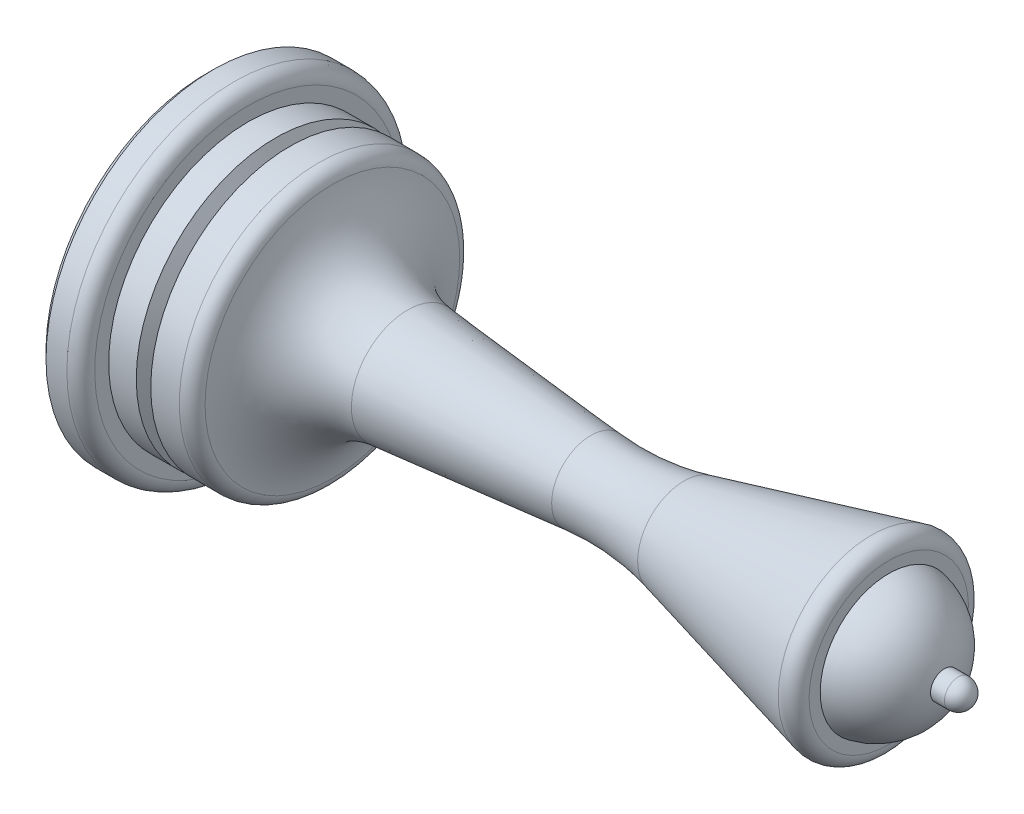
from build123d import *

# Parameters (mm, degrees)
SKETCH3_R          = 6
CUT_EXTRUDE1_DEPTH = 5
FILLET1_R          = 1


with BuildPart() as part:
    # Sketch1 → Revolve1 (revolve)
    with BuildSketch(Plane.XY, mode=Mode.PRIVATE) as revolve1_sk:
        with BuildLine():
            Line((0, 0), (0, 11.5))
            Line((0, 11.5), (0.5, 12))
            Line((0.5, 12), (2, 12))
            ThreePointArc((2, 12), (2.707106781, 11.707106781), (3, 11))
            Line((3, 11), (3, 10))
            Line((3, 10), (8.07179677, 10))
            ThreePointArc((8.07179677, 10), (8.72645044, 9.755928946), (9.061540088, 9.142857143))
            ThreePointArc((9.061540088, 9.142857143), (10.867885048, 5.649640702), (14.449368595, 4.025319669))
            Line((14.449368595, 4.025319669), (27.613327767, 2.812118471))
            ThreePointArc((27.613327767, 2.812118471), (30.978046162, 2.786272748), (34.299478284, 3.324869571))
            Line((34.299478284, 3.324869571), (49, 7))
            Line((49, 7), (49, 4.918519684))
            ThreePointArc((49, 4.918519684), (51.599989103, 3.571724907), (53, 1))
            Line((53, 1), (54, 1))
            ThreePointArc((54, 1), (54.707106781, 0.707106781), (55, 0))
            Line((55, 0), (0, 0))
        make_face()
    revolve(revolve1_sk.sketch.rotate(Axis((0, 0, 0), (1, 0, 0)), 180), axis=Axis((0, 0, 0), (1, 0, 0)))  # turned: the seam where the file's is

    # Sketch2 → Cut-Revolve1 (revolve, cut)
    with BuildSketch(Plane.XY, mode=Mode.PRIVATE) as cut_revolve1_sk:
        Polygon((4.979432949, 10), (5.5, 9), (6.020567051, 10), align=None)
    revolve(cut_revolve1_sk.sketch.rotate(Axis((0, 0, 0), (1, 0, 0)), 180), axis=Axis((0, 0, 0), (1, 0, 0)), mode=Mode.SUBTRACT)  # turned: the seam where the file's is

    # Sketch3 → Cut-Extrude1 (cut)
    with BuildSketch(Plane.ZY):
        with Locations(Location((0, 0, 0), (0, 0, 270))):  # turned: the seam where the file's is
            Circle(SKETCH3_R)
    extrude(amount=-CUT_EXTRUDE1_DEPTH, mode=Mode.SUBTRACT)

    # Fillet1
    fillet1_edges = [part.edges().sort_by_distance(p)[0] for p in [
        (49, 7, 0),
    ]]
    fillet(fillet1_edges, radius=FILLET1_R)


solid = part.part
